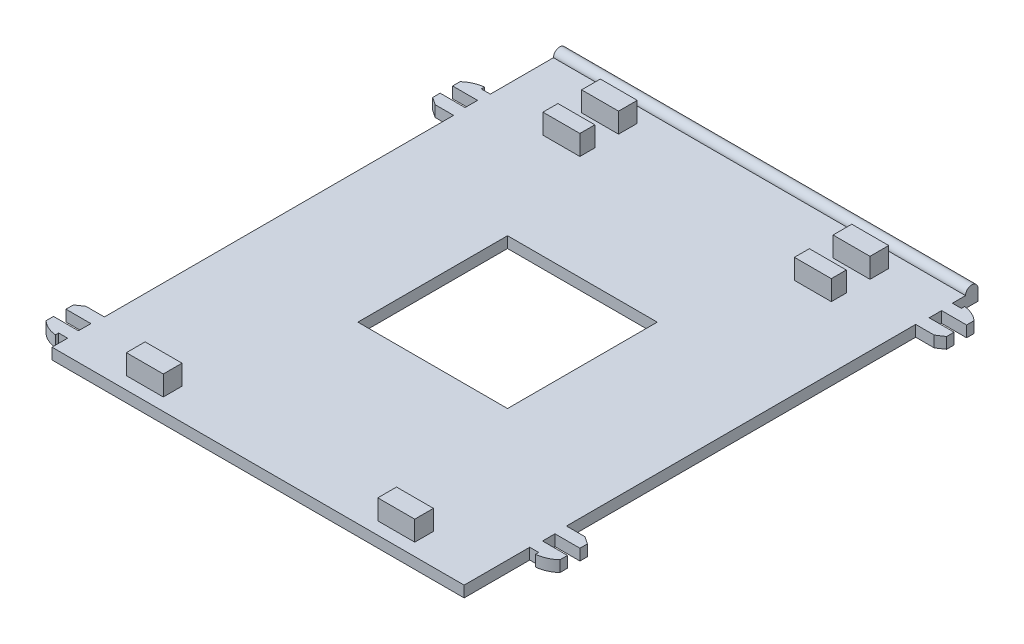
from build123d import *

# Parameters (mm, degrees)
SKETCH1_W           = 0.2
SKETCH1_H           = 2.5
SKETCH1_W_2         = 82.6
SKETCH1_H_2         = 100
BOSS_EXTRUDE1_DEPTH = 2.23
SKETCH2_W           = 7.4
SKETCH2_H           = 3.75
SKETCH2_H_2         = 3
BOSS_EXTRUDE2_DEPTH = 4
SKETCH3_W           = 30
SKETCH3_H           = 30
CUT_EXTRUDE1_DEPTH  = 10
BOSS_EXTRUDE3_START = -82.6
SKETCH4_W           = 3
SKETCH4_H           = 2.23
BOSS_EXTRUDE3_DEPTH = 82.6
CUT_EXTRUDE2_DEPTH  = 0.5


with BuildPart() as part:
    # Sketch1 → Boss-Extrude1 (new body)
    with BuildSketch(Plane(origin=(0, 0, 0), x_dir=(1, 0, 0), z_dir=(0, 1, 0))):
        with BuildLine():
            Line((43.1, -36.85), (43.1, -37.5))
            ThreePointArc((43.1, -37.5), (44.922195524, -37.020142239), (46.5, -35.99))
            Line((46.5, -35.99), (46.5, -34.49))
            Line((46.5, -34.49), (43.1, -34.49))
            Line((43.1, -34.49), (43.1, -36.85))
        make_face()
        Polygon((41.5, -34.49), (41.3, -34.49), (41.3, -36.85), (43.1, -36.85), (43.1, -34.49), align=None)
        Polygon((45, -29.49), (41.3, -29.49), (41.3, -31.99), (41.5, -31.99), (46.5, -31.99), (46.5, -30.49), align=None)
        with Locations((41.4, -33.24)):
            Rectangle(SKETCH1_W, SKETCH1_H)
        Rectangle(SKETCH1_W_2, SKETCH1_H_2)
        Polygon((46.5, 43.01), (41.5, 43.01), (41.3, 43.01), (41.3, 40.51), (45, 40.51), (46.5, 41.51), align=None)
        with Locations((41.4, 44.26)):
            Rectangle(SKETCH1_W, SKETCH1_H)
        Polygon((41.5, 45.51), (43.1, 45.51), (43.1, 47.87), (41.3, 47.87), (41.3, 45.51), align=None)
        with BuildLine():
            ThreePointArc((43.1, 48.52), (44.922195524, 48.040142239), (46.5, 47.01))
            Line((46.5, 47.01), (46.5, 45.51))
            Line((46.5, 45.51), (43.1, 45.51))
            Line((43.1, 45.51), (43.1, 47.87))
            Line((43.1, 47.87), (43.1, 48.52))
        make_face()
        with BuildLine():
            Line((-43.1, -46.87), (-41.3, -46.87))
            Line((-41.3, -46.87), (-41.3, -44.51))
            Line((-41.3, -44.51), (-41.5, -44.51))
            Line((-41.5, -44.51), (-46.5, -44.51))
            Line((-46.5, -44.51), (-46.5, -46.01))
            ThreePointArc((-46.5, -46.01), (-44.922195524, -47.040142239), (-43.1, -47.52))
            Line((-43.1, -47.52), (-43.1, -46.87))
        make_face()
        Polygon((-41.3, -44.51), (-41.3, -39.51), (-45, -39.51), (-46.5, -40.51), (-46.5, -42.01), (-41.5, -42.01), (-41.5, -44.51), align=None)
        Polygon((-41.3, 30.49), (-41.3, 35.49), (-41.5, 35.49), (-41.5, 32.99), (-46.5, 32.99), (-46.5, 31.49), (-45, 30.49), align=None)
        with BuildLine():
            Line((-41.3, 35.49), (-41.3, 37.85))
            Line((-41.3, 37.85), (-43.1, 37.85))
            Line((-43.1, 37.85), (-43.1, 38.5))
            ThreePointArc((-43.1, 38.5), (-44.922195524, 38.020142239), (-46.5, 36.99))
            Line((-46.5, 36.99), (-46.5, 35.49))
            Line((-46.5, 35.49), (-41.5, 35.49))
            Line((-41.5, 35.49), (-41.3, 35.49))
        make_face()
    extrude(amount=BOSS_EXTRUDE1_DEPTH)

    # Sketch2 → Boss-Extrude2 (add)
    with BuildSketch(Plane(origin=(0, 2.23, 0), x_dir=(1, 0, 0), z_dir=(0, 1, 0))):
        with Locations((-25.2, -45.625)):
            Rectangle(SKETCH2_W, SKETCH2_H)
        with Locations((25.2, -45.625)):
            Rectangle(SKETCH2_W, SKETCH2_H)
        with Locations((25.2, 45.625)):
            Rectangle(SKETCH2_W, SKETCH2_H)
        with Locations((-25.2, 45.625)):
            Rectangle(SKETCH2_W, SKETCH2_H)
        with Locations((-25.2, 37.5)):
            Rectangle(SKETCH2_W, SKETCH2_H_2)
        with Locations((25.2, 37.5)):
            Rectangle(SKETCH2_W, SKETCH2_H_2)
    extrude(amount=BOSS_EXTRUDE2_DEPTH)

    # Sketch3 → Cut-Extrude1 (cut)
    with BuildSketch(Plane(origin=(0, 2.23, 0), x_dir=(1, 0, 0), z_dir=(0, 1, 0))):
        Rectangle(SKETCH3_W, SKETCH3_H)
    extrude(amount=-CUT_EXTRUDE1_DEPTH, mode=Mode.SUBTRACT)

    # Sketch4 → Boss-Extrude3 (add)
    with BuildSketch(Plane.ZY.offset(41.3).offset(BOSS_EXTRUDE3_START)):
        with BuildLine():
            ThreePointArc((-50.5, 2.23), (-51.75, 3.48), (-53, 2.23))
            Line((-53, 2.23), (-50.5, 2.23))
        make_face()
        with Locations((-51.5, 1.115)):
            Rectangle(SKETCH4_W, SKETCH4_H)
    extrude(amount=BOSS_EXTRUDE3_DEPTH)

    # Sketch5 → Cut-Extrude2 (cut)
    with BuildSketch(Plane.XZ):
        Polygon((4.640384615, -43.419230769), (4.640384615, -45.291666667), (4.070512821, -45.291666667), (4.070512821, -43.419230769), (2.198076923, -43.419230769), (2.198076923, -42.849358974), (4.070512821, -42.849358974), (4.070512821, -40.976923077), (4.640384615, -40.976923077), (4.640384615, -42.849358974), (6.512820513, -42.849358974), (6.512820513, -43.419230769), align=None)
        Polygon((1.221153846, -45.698717949), (1.221153846, -46.35), (-2.116666667, -46.35), (0.54697516, -40.651282051), (-2.03525641, -40.651282051), (-2.03525641, -40), (1.465384615, -40), (-1.198257212, -45.698717949), align=None)
        with BuildLine():
            add(Edge.make_bspline(
                [(-3.175, -44.482652244), (-3.262918211, -44.565594294), (-3.433284709, -44.726318068), (-3.671176807, -44.969181062), (-3.884395029, -45.204215059), (-4.071386431, -45.432230465), (-4.235563138, -45.650653984), (-4.373446797, -45.862117777), (-4.487450991, -46.065713922), (-4.546079998, -46.202765549), (-4.574238782, -46.268589744)],
                knots=[0, 0, 0, 0, 0.000362575, 0.000702591, 0.001019617, 0.001314251, 0.001586978, 0.001838892, 0.00207117, 0.002285828, 0.002285828, 0.002285828, 0.002285828], degree=3))
            Line((-4.574238782, -46.268589744), (-4.759955929, -46.268589744))
            add(Edge.make_bspline(
                [(-4.759955929, -46.268589744), (-4.792788221, -46.198486652), (-4.860615985, -46.053661673), (-4.986779978, -45.841364869), (-5.132525091, -45.623706079), (-5.300867212, -45.402881295), (-5.491310702, -45.177687257), (-5.702118152, -44.94759275), (-5.93585869, -44.714525691), (-6.101847246, -44.561381426), (-6.187179487, -44.482652244)],
                knots=[0, 0, 0, 0, 0.000232111, 0.000479514, 0.000739881, 0.001017698, 0.001312003, 0.001624408, 0.001953613, 0.002301902, 0.002301902, 0.002301902, 0.002301902], degree=3))
            Line((-6.187179487, -44.482652244), (-6.187179487, -44.151923077))
            add(Edge.make_bspline(
                [(-6.187179487, -44.151923077), (-6.116537815, -44.184471117), (-5.978890638, -44.247891839), (-5.781903944, -44.34935602), (-5.597143614, -44.448436612), (-5.427913951, -44.551377879), (-5.270864773, -44.651733434), (-5.129759329, -44.755968393), (-5.000056754, -44.857829341), (-4.922299946, -44.930706152), (-4.884615385, -44.966025641)],
                knots=[0, 0, 0, 0, 0.000233307, 0.000454604, 0.000664648, 0.000862076, 0.001048719, 0.001223511, 0.001388199, 0.001543075, 0.001543075, 0.001543075, 0.001543075], degree=3))
            Line((-4.884615385, -44.966025641), (-4.884615385, -38.127564103))
            Line((-4.884615385, -38.127564103), (-4.477564103, -38.127564103))
            Line((-4.477564103, -38.127564103), (-4.477564103, -44.966025641))
            add(Edge.make_bspline(
                [(-4.477564103, -44.966025641), (-4.378031962, -44.888388472), (-4.177950241, -44.732320508), (-3.858882125, -44.521130617), (-3.525108924, -44.32477265), (-3.292360048, -44.209864), (-3.175, -44.151923077)],
                knots=[0, 0, 0, 0, 0.000378565, 0.000760999, 0.001146938, 0.001539469, 0.001539469, 0.001539469, 0.001539469], degree=3))
            Line((-3.175, -44.151923077), (-3.175, -44.482652244))
        make_face()
    extrude(amount=-CUT_EXTRUDE2_DEPTH, mode=Mode.SUBTRACT)


solid = part.part
